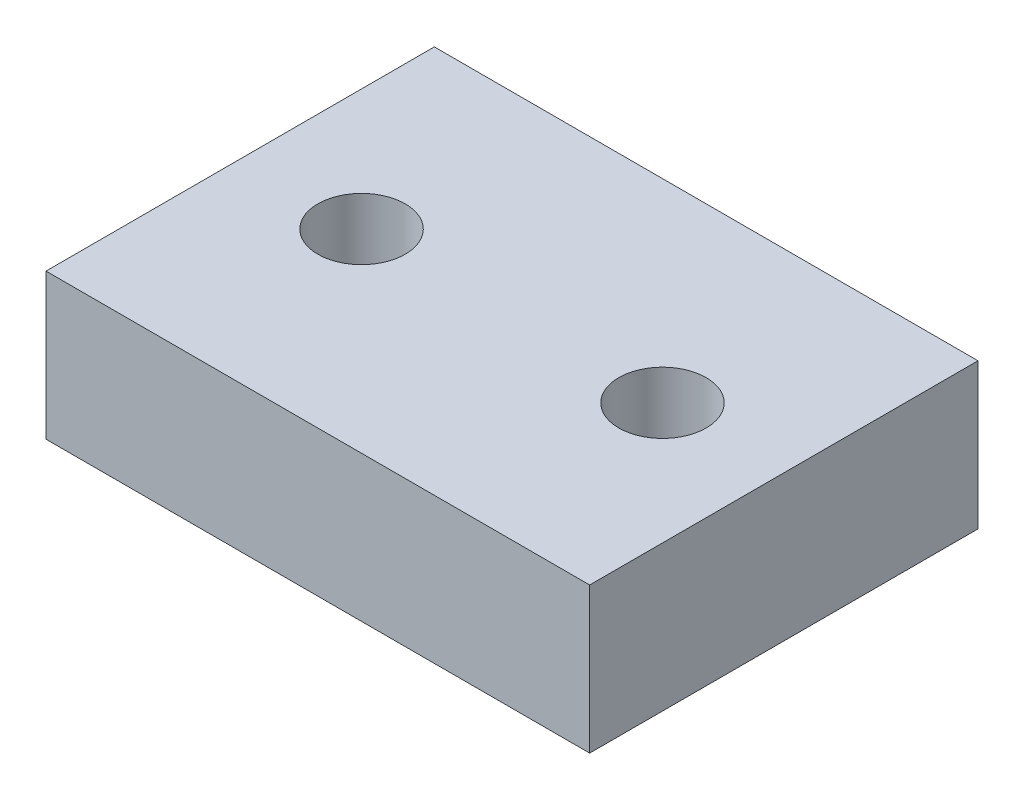
from build123d import *

# Parameters (mm, degrees)
SKETCH1_W           = 28
SKETCH1_H           = 20
SKETCH1_R           = 2.25
BOSS_EXTRUDE1_DEPTH = 3.75


with BuildPart() as part:
    # Sketch1 → Boss-Extrude1 (new body, symmetric)
    with BuildSketch(Plane(origin=(0, 0, 0), x_dir=(1, 0, 0), z_dir=(0, 1, 0))):
        Rectangle(SKETCH1_W, SKETCH1_H)
        with Locations((-7.75, 0)):
            Circle(SKETCH1_R, mode=Mode.SUBTRACT)
        with Locations((7.75, 0)):
            Circle(SKETCH1_R, mode=Mode.SUBTRACT)
    extrude(amount=BOSS_EXTRUDE1_DEPTH, both=True)


solid = part.part
